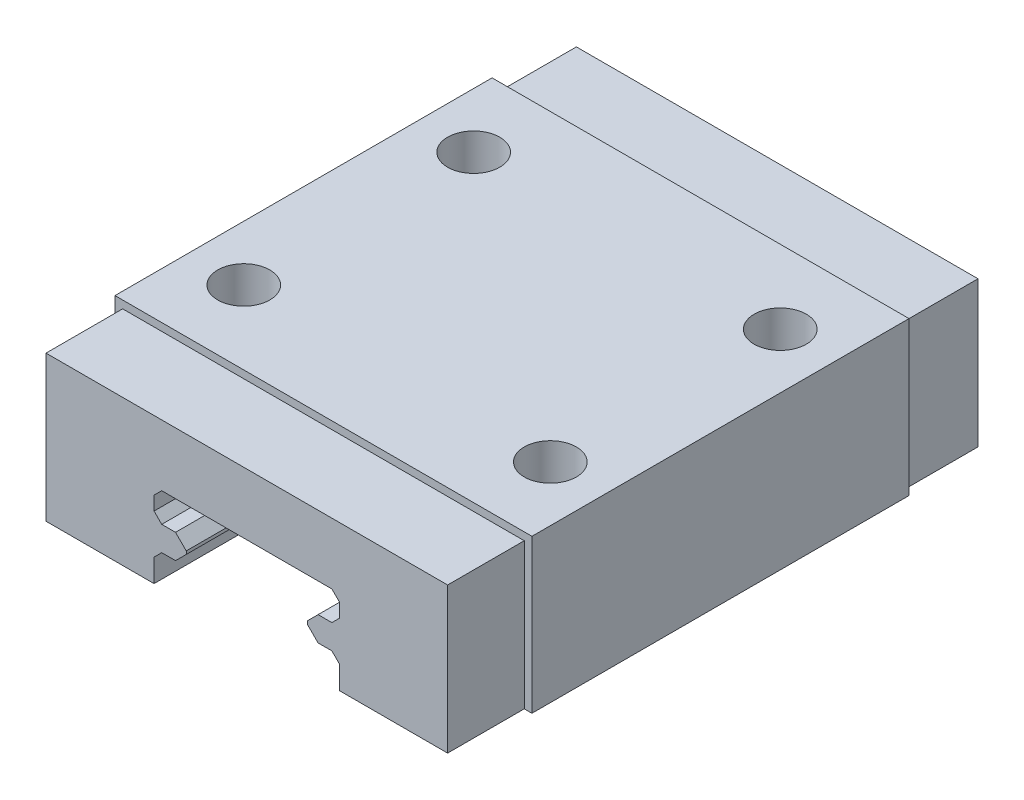
from build123d import *

# Parameters (mm, degrees)
SKETCH1_W                = 27.2
SKETCH1_H                = 10
BOSS_EXTRUDE1_DEPTH      = 34.6
CUT_EXTRUDE1_DEPTH       = 1
CUT_EXTRUDE1_DEPTH_BACK  = 34.6
CHAMFER1_SIZE            = 0.7
M3_CLEARANCE_HOLE1_D     = 3.4
M3_CLEARANCE_HOLE1_DEPTH = 5
M3_CLEARANCE_HOLE1_TIP   = 1.021463052
SKETCH7_W                = 27.2
SKETCH7_H                = 5
CUT_EXTRUDE2_DEPTH       = 0.5
SKETCH8_W                = 5
SKETCH8_H                = 9.5
CUT_EXTRUDE3_DEPTH       = 0.5


with BuildPart() as part:
    # Sketch1 → Boss-Extrude1 (new body)
    with BuildSketch(Plane.XY):
        Rectangle(SKETCH1_W, SKETCH1_H)
    extrude(amount=BOSS_EXTRUDE1_DEPTH)

    # Sketch2 → Cut-Extrude1 (cut, two sides)
    with BuildSketch(Plane.XY.offset(34.6)) as cut_extrude1_sk:
        Polygon((-5.55, -3), (-6.05, -3.5), (-6.05, -5), (6.05, -5), (6.05, -3.5), (5.55, -3), (3.95, -3), (3.95, -1.4), (5.55, -1.4), (6.05, -0.9), (6.05, 0), (5.55, 0.5), (-5.55, 0.5), (-6.05, 0), (-6.05, -0.9), (-5.55, -1.4), (-3.95, -1.4), (-3.95, -3), align=None)
    extrude(amount=CUT_EXTRUDE1_DEPTH, mode=Mode.SUBTRACT)
    extrude(cut_extrude1_sk.sketch, amount=-CUT_EXTRUDE1_DEPTH_BACK, mode=Mode.SUBTRACT)

    # Chamfer1
    chamfer1_edges = [part.edges().sort_by_distance(p)[0] for p in [
        (-3.95, -3, 17.3),
        (3.95, -3, 17.3),
        (3.95, -1.4, 17.3),
        (-3.95, -1.4, 17.3),
    ]]
    chamfer(chamfer1_edges, length=CHAMFER1_SIZE)

    # M3 Clearance Hole1
    with Locations(Plane(origin=(0, 5, 0), x_dir=(1, 0, 0), z_dir=(0, 1, 0))):
        with Locations((-10, -24.8), (-10, -9.8), (10, -9.8), (10, -24.8)):
            Hole(M3_CLEARANCE_HOLE1_D / 2, depth=M3_CLEARANCE_HOLE1_DEPTH)
            with Locations((0, 0, -(M3_CLEARANCE_HOLE1_DEPTH + M3_CLEARANCE_HOLE1_TIP / 2))):  # 118° drill point
                Cone(0, M3_CLEARANCE_HOLE1_D / 2, M3_CLEARANCE_HOLE1_TIP, mode=Mode.SUBTRACT)

    # Sketch7 → Cut-Extrude2 (cut)
    with BuildSketch(Plane(origin=(0, 5, 0), x_dir=(1, 0, 0), z_dir=(0, 1, 0))):
        with Locations((0, -32.1)):
            Rectangle(SKETCH7_W, SKETCH7_H)
        with Locations((0, -2.5)):
            Rectangle(SKETCH7_W, SKETCH7_H)
    extrude(amount=-CUT_EXTRUDE2_DEPTH, mode=Mode.SUBTRACT)

    # Sketch8 → Cut-Extrude3 (cut)
    with BuildSketch(Plane(origin=(13.6, 0, 0), x_dir=(0, 0, -1), z_dir=(1, 0, 0))):
        with Locations((-32.1, -0.25)):
            Rectangle(SKETCH8_W, SKETCH8_H)
        with Locations((-2.5, -0.25)):
            Rectangle(SKETCH8_W, SKETCH8_H)
    cut_extrude3 = extrude(amount=-CUT_EXTRUDE3_DEPTH, mode=Mode.SUBTRACT)

    # Mirror1: Cut-Extrude3 across plane
    add(cut_extrude3.mirror(Plane(origin=(0, 0, 0), x_dir=(0, 0, 1), z_dir=(1, 0, 0))), mode=Mode.SUBTRACT)


solid = part.part
